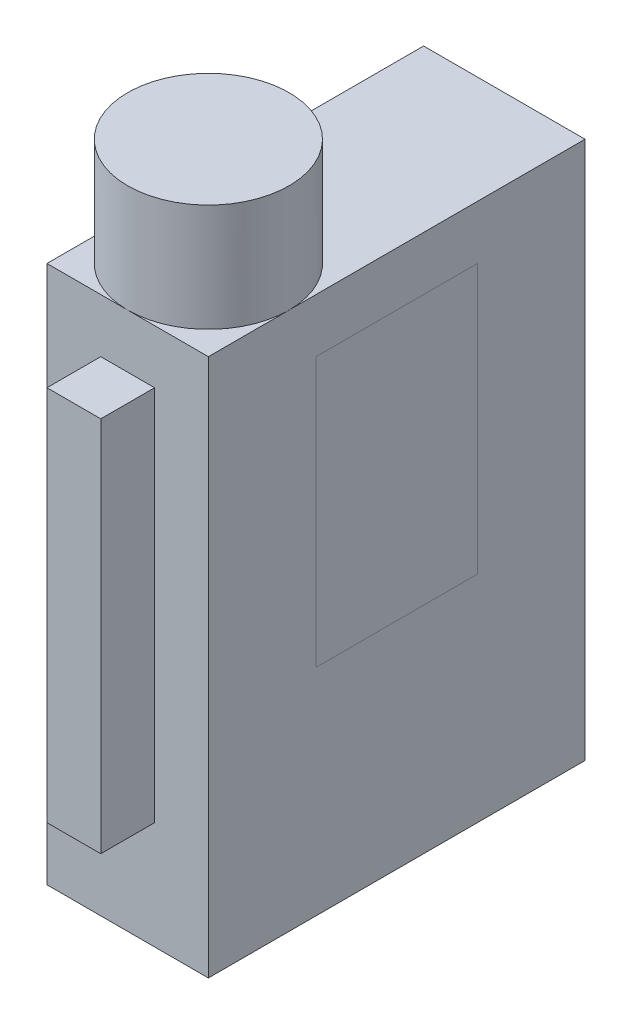
from build123d import *

# Parameters (mm, degrees)
SKETCH1_W           = 30
SKETCH1_H           = 100
BOSS_EXTRUDE1_DEPTH = 70
SKETCH2_W           = 10
SKETCH2_H           = 70
BOSS_EXTRUDE2_DEPTH = 10
SKETCH3_R           = 15
BOSS_EXTRUDE3_DEPTH = 20


with BuildPart() as part:
    # Sketch1 → Boss-Extrude1 (new body)
    with BuildSketch(Plane.XY):
        with Locations((15, 50)):
            Rectangle(SKETCH1_W, SKETCH1_H)
    extrude(amount=BOSS_EXTRUDE1_DEPTH)

    # Sketch2 → Boss-Extrude2 (add)
    with BuildSketch(Plane.XY.offset(70)):
        with Locations((15, 55)):
            Rectangle(SKETCH2_W, SKETCH2_H)
    extrude(amount=BOSS_EXTRUDE2_DEPTH)

    # Sketch3 → Boss-Extrude3 (add)
    with BuildSketch(Plane(origin=(0, 100, 0), x_dir=(1, 0, 0), z_dir=(0, 1, 0))):
        with Locations(Location((15, -55, 0), (0, 0, 270))):  # turned: the seam where the file's is
            Circle(SKETCH3_R)
    extrude(amount=BOSS_EXTRUDE3_DEPTH)


solid = part.part
